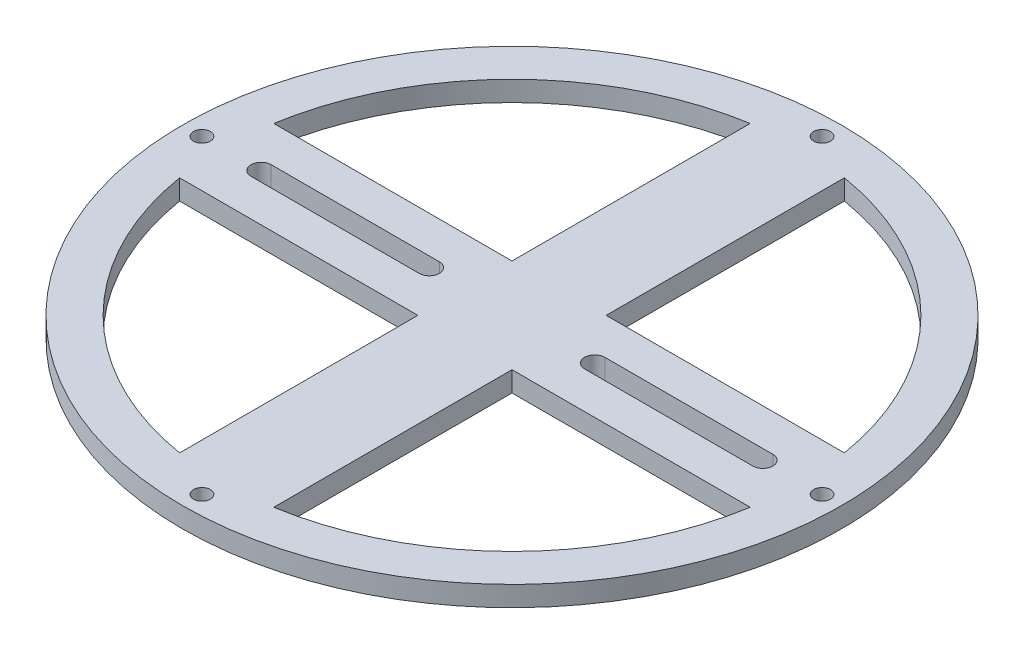
from build123d import *

# Parameters (mm, degrees)
SKETCH_1_R               = 49
EXTRUDE_1_DEPTH          = 3
CUT_EXTRUDE_3_DEPTH      = 4
CUT_EXTRUDE_4_DEPTH      = 4
PATTERN_CIRCULAR_4_COUNT = 2
SKETCH_2_R               = 1.25
CUT_EXTRUDE_5_DEPTH      = 4
PATTERN_CIRCULAR_5_COUNT = 4
PATTERN_CIRCULAR_6_COUNT = 4


with BuildPart() as part:
    # 草图1 → 凸台-拉伸1 (new body)
    with BuildSketch(Plane(origin=(0, 0, 0), x_dir=(1, 0, 0), z_dir=(0, 1, 0))):
        Circle(SKETCH_1_R)
    extrude(amount=EXTRUDE_1_DEPTH)

    # 草图5 → 切除-拉伸3 (cut, through all)
    with BuildSketch(Plane(origin=(0, 3, 0), x_dir=(1, 0, 0), z_dir=(0, 1, 0))):
        with BuildLine():
            Line((7, 42.420036355), (7, 7))
            Line((7, 7), (42.420036355, 7))
            ThreePointArc((42.420036355, 7), (30.401147054, 30.401147054), (7, 42.420036355))
        make_face()
    cut_extrude_3 = extrude(amount=-CUT_EXTRUDE_3_DEPTH, mode=Mode.SUBTRACT)

    # 草图6 → 切除-拉伸4 (cut, through all)
    with BuildSketch(Plane(origin=(0, 3, 0), x_dir=(1, 0, 0), z_dir=(0, 1, 0))):
        with BuildLine():
            Line((-12.3, -1.5), (-37.3, -1.5))
            ThreePointArc((-37.3, -1.5), (-38.8, 0), (-37.3, 1.5))
            Line((-37.3, 1.5), (-12.3, 1.5))
            ThreePointArc((-12.3, 1.5), (-10.8, 0), (-12.3, -1.5))
        make_face()
    cut_extrude_4 = extrude(amount=-CUT_EXTRUDE_4_DEPTH, mode=Mode.SUBTRACT)

    # 阵列(圆周)4: 切除-拉伸4 ×2 about axis
    pattern_circular_4_axis = Axis((0, 0, 0), (0, 1, 0))
    for i in range(1, PATTERN_CIRCULAR_4_COUNT):
        add(cut_extrude_4.rotate(pattern_circular_4_axis, i * 360 / PATTERN_CIRCULAR_4_COUNT), mode=Mode.SUBTRACT)

    # 草图2 → 切除-拉伸5 (cut, through all)
    with BuildSketch(Plane(origin=(0, 3, 0), x_dir=(1, 0, 0), z_dir=(0, 1, 0))):
        with Locations((0, 46.1)):
            Circle(SKETCH_2_R)
    cut_extrude_5 = extrude(amount=-CUT_EXTRUDE_5_DEPTH, mode=Mode.SUBTRACT)

    # 阵列(圆周)5: 切除-拉伸5 ×4 about axis
    pattern_circular_5_axis = Axis((0, 0, 0), (0, 1, 0))
    for i in range(1, PATTERN_CIRCULAR_5_COUNT):
        add(cut_extrude_5.rotate(pattern_circular_5_axis, i * 360 / PATTERN_CIRCULAR_5_COUNT), mode=Mode.SUBTRACT)

    # 阵列(圆周)6: 切除-拉伸3 ×4 about axis
    pattern_circular_6_axis = Axis((0, 0, 0), (0, 1, 0))
    for i in range(1, PATTERN_CIRCULAR_6_COUNT):
        add(cut_extrude_3.rotate(pattern_circular_6_axis, i * 360 / PATTERN_CIRCULAR_6_COUNT), mode=Mode.SUBTRACT)


solid = part.part
